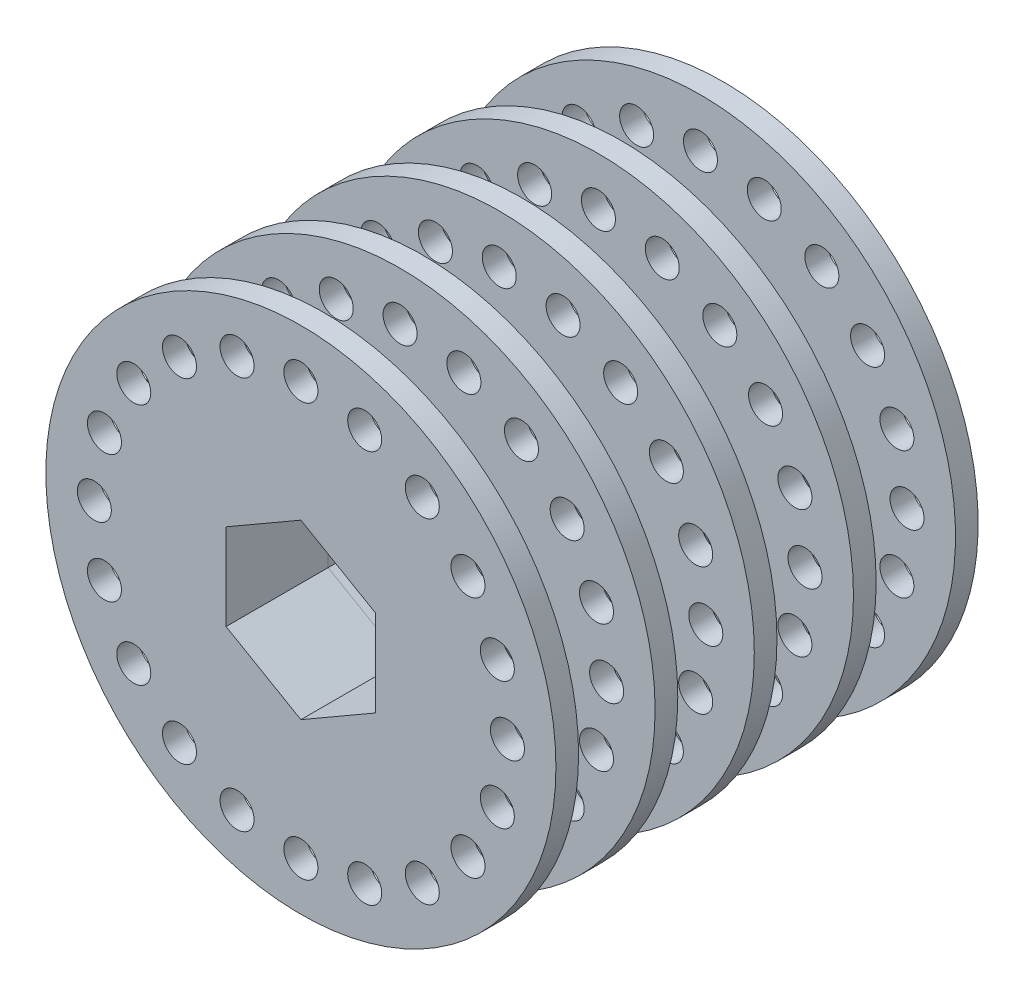
from build123d import *

# Parameters (mm, degrees)
SKETCH1_R           = 22.5
SKETCH1_R_2         = 1.5
BOSS_EXTRUDE1_DEPTH = 2
SKETCH1_3_R         = 10.16
BOSS_EXTRUDE2_DEPTH = 7
LPATTERN2_COUNT     = 4
LPATTERN2_PITCH     = 8.75
BOSS_EXTRUDE3_START = 2
SKETCH2_R           = 22.5
SKETCH2_R_2         = 1.5
BOSS_EXTRUDE3_DEPTH = 2
CUT_EXTRUDE1_DEPTH  = 49.990432739


with BuildPart() as part:
    # Sketch1 → Boss-Extrude1 (new body)
    with BuildSketch(Plane.XY):
        Circle(SKETCH1_R)
        with Locations((-5.630860181, -17.330005678)):
            Circle(SKETCH1_R_2, mode=Mode.SUBTRACT)
        with Locations((-10.710532534, -14.741783339)):
            Circle(SKETCH1_R_2, mode=Mode.SUBTRACT)
        with Locations((-17.330005678, -5.630860181)):
            Circle(SKETCH1_R_2, mode=Mode.SUBTRACT)
        with Locations((-14.741783339, -10.710532534)):
            Circle(SKETCH1_R_2, mode=Mode.SUBTRACT)
        with Locations((-18.221846316, 0)):
            Circle(SKETCH1_R_2, mode=Mode.SUBTRACT)
        with Locations((0, -18.221846316)):
            Circle(SKETCH1_R_2, mode=Mode.SUBTRACT)
        with Locations((5.630860181, -17.330005678)):
            Circle(SKETCH1_R_2, mode=Mode.SUBTRACT)
        with Locations((10.710532534, -14.741783339)):
            Circle(SKETCH1_R_2, mode=Mode.SUBTRACT)
        with Locations((14.741783339, -10.710532534)):
            Circle(SKETCH1_R_2, mode=Mode.SUBTRACT)
        with Locations((17.330005678, -5.630860181)):
            Circle(SKETCH1_R_2, mode=Mode.SUBTRACT)
        with Locations((-17.330005678, 5.630860181)):
            Circle(SKETCH1_R_2, mode=Mode.SUBTRACT)
        with Locations((-14.741783339, 10.710532534)):
            Circle(SKETCH1_R_2, mode=Mode.SUBTRACT)
        with Locations((-10.710532534, 14.741783339)):
            Circle(SKETCH1_R_2, mode=Mode.SUBTRACT)
        with Locations((-5.630860181, 17.330005678)):
            Circle(SKETCH1_R_2, mode=Mode.SUBTRACT)
        with Locations((5.630860181, 17.330005678)):
            Circle(SKETCH1_R_2, mode=Mode.SUBTRACT)
        with Locations((18.221846316, 0)):
            Circle(SKETCH1_R_2, mode=Mode.SUBTRACT)
        with Locations((14.741783339, 10.710532534)):
            Circle(SKETCH1_R_2, mode=Mode.SUBTRACT)
        with Locations((17.330005678, 5.630860181)):
            Circle(SKETCH1_R_2, mode=Mode.SUBTRACT)
        with Locations((10.710532534, 14.741783339)):
            Circle(SKETCH1_R_2, mode=Mode.SUBTRACT)
        with Locations((0, 18.221846316)):
            Circle(SKETCH1_R_2, mode=Mode.SUBTRACT)
    extrude(amount=BOSS_EXTRUDE1_DEPTH)

    # Sketch1_3 → Boss-Extrude2 (add)
    with BuildSketch(Plane.XY):
        Circle(SKETCH1_3_R)
    extrude(amount=-BOSS_EXTRUDE2_DEPTH)


with BuildPart() as lpattern2_1:
    # LPattern2: pattern copy
    add(part.part.moved(Location(Vector(0, 0, -1) * (1 * LPATTERN2_PITCH))))


with BuildPart() as lpattern2_2:
    # LPattern2: pattern copy
    add(part.part.moved(Location(Vector(0, 0, -1) * (2 * LPATTERN2_PITCH))))


with BuildPart() as lpattern2_3:
    # LPattern2: pattern copy
    add(part.part.moved(Location(Vector(0, 0, -1) * (3 * LPATTERN2_PITCH))))

    # Sketch2 → Boss-Extrude3 (add)
    with BuildSketch(Plane(origin=(0, 0, -33.25), x_dir=(-1, 0, 0), z_dir=(0, 0, -1)).offset(BOSS_EXTRUDE3_START)):
        Circle(SKETCH2_R)
        with Locations((-5.630860181, -17.330005678)):
            Circle(SKETCH2_R_2, mode=Mode.SUBTRACT)
        with Locations((0, -18.221846316)):
            Circle(SKETCH2_R_2, mode=Mode.SUBTRACT)
        with Locations((-10.710532534, -14.741783339)):
            Circle(SKETCH2_R_2, mode=Mode.SUBTRACT)
        with Locations((-17.330005678, -5.630860181)):
            Circle(SKETCH2_R_2, mode=Mode.SUBTRACT)
        with Locations((-14.741783339, -10.710532534)):
            Circle(SKETCH2_R_2, mode=Mode.SUBTRACT)
        with Locations((5.630860181, -17.330005678)):
            Circle(SKETCH2_R_2, mode=Mode.SUBTRACT)
        with Locations((10.710532534, -14.741783339)):
            Circle(SKETCH2_R_2, mode=Mode.SUBTRACT)
        with Locations((14.741783339, -10.710532534)):
            Circle(SKETCH2_R_2, mode=Mode.SUBTRACT)
        with Locations((17.330005678, -5.630860181)):
            Circle(SKETCH2_R_2, mode=Mode.SUBTRACT)
        with Locations((18.221846316, 0)):
            Circle(SKETCH2_R_2, mode=Mode.SUBTRACT)
        with Locations((-18.221846316, 0)):
            Circle(SKETCH2_R_2, mode=Mode.SUBTRACT)
        with Locations((-17.330005678, 5.630860181)):
            Circle(SKETCH2_R_2, mode=Mode.SUBTRACT)
        with Locations((-14.741783339, 10.710532534)):
            Circle(SKETCH2_R_2, mode=Mode.SUBTRACT)
        with Locations((-10.710532534, 14.741783339)):
            Circle(SKETCH2_R_2, mode=Mode.SUBTRACT)
        with Locations((-5.630860181, 17.330005678)):
            Circle(SKETCH2_R_2, mode=Mode.SUBTRACT)
        with Locations((5.630860181, 17.330005678)):
            Circle(SKETCH2_R_2, mode=Mode.SUBTRACT)
        with Locations((14.741783339, 10.710532534)):
            Circle(SKETCH2_R_2, mode=Mode.SUBTRACT)
        with Locations((17.330005678, 5.630860181)):
            Circle(SKETCH2_R_2, mode=Mode.SUBTRACT)
        with Locations((10.710532534, 14.741783339)):
            Circle(SKETCH2_R_2, mode=Mode.SUBTRACT)
        with Locations((0, 18.221846316)):
            Circle(SKETCH2_R_2, mode=Mode.SUBTRACT)
    extrude(amount=-BOSS_EXTRUDE3_DEPTH)


with BuildPart() as cut_extrude1_tool:
    # Sketch3 → Cut-Extrude1 (new, through all)
    with BuildSketch(Plane(origin=(0, 0, -35.25), x_dir=(-1, 0, 0), z_dir=(0, 0, -1))):
        Polygon((6.6, 3.810511777), (0, 7.621023553), (-6.6, 3.810511777), (-6.6, -3.810511777), (0, -7.621023553), (6.6, -3.810511777), align=None)
    extrude(amount=-CUT_EXTRUDE1_DEPTH)


with BuildPart() as part_1:
    add(part.part)

    # Cut-Extrude1: cut by cut_extrude1_tool
    add(cut_extrude1_tool.part, mode=Mode.SUBTRACT)


with BuildPart() as lpattern2_1_1:
    add(lpattern2_1.part)

    # Cut-Extrude1: cut by cut_extrude1_tool
    add(cut_extrude1_tool.part, mode=Mode.SUBTRACT)


with BuildPart() as lpattern2_2_1:
    add(lpattern2_2.part)

    # Cut-Extrude1: cut by cut_extrude1_tool
    add(cut_extrude1_tool.part, mode=Mode.SUBTRACT)


with BuildPart() as lpattern2_3_1:
    add(lpattern2_3.part)

    # Cut-Extrude1: cut by cut_extrude1_tool
    add(cut_extrude1_tool.part, mode=Mode.SUBTRACT)


solid = Compound([part_1.part, lpattern2_1_1.part, lpattern2_2_1.part, lpattern2_3_1.part])
